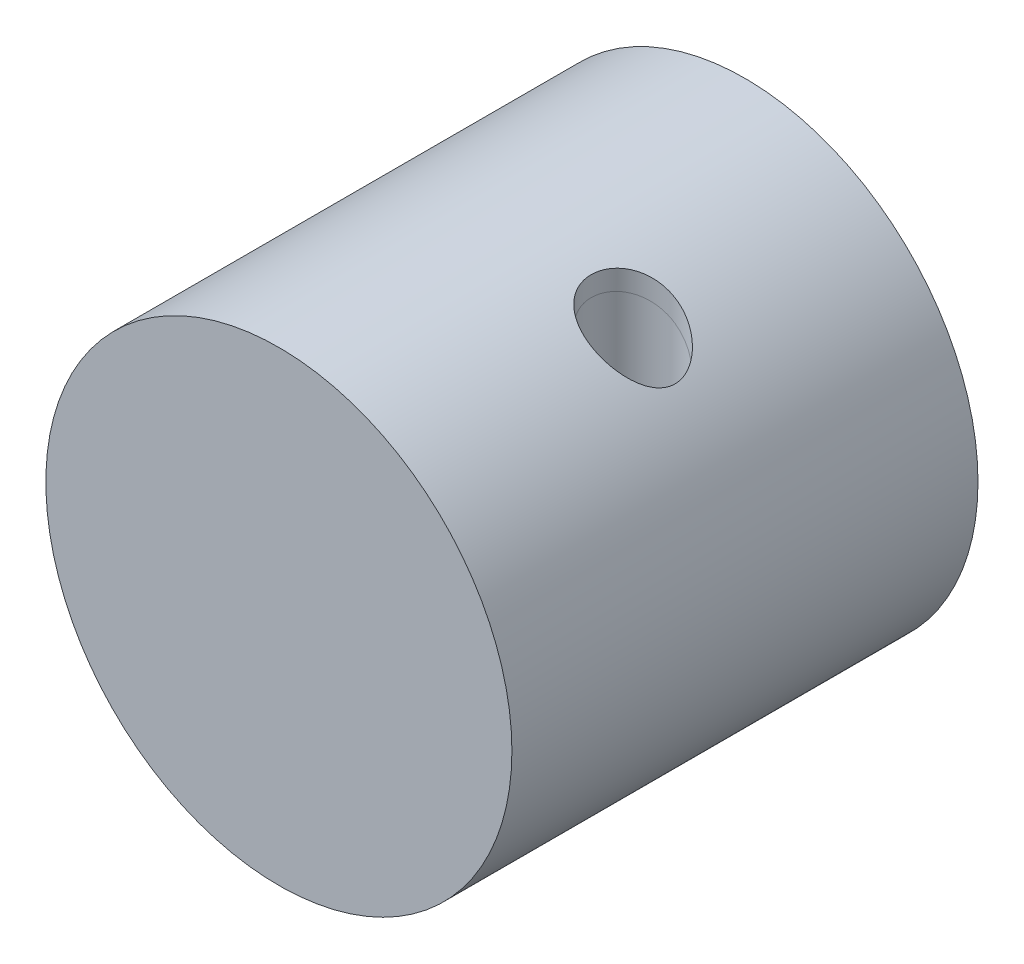
from build123d import *

# Parameters (mm, degrees)
SKIZZE1_R                       = 25
AUFSATZ_LINEAR_AUSTRAGEN1_DEPTH = 25
SKIZZE2_R                       = 4.5
SCHNITT_LINEAR_AUSTRAGEN1_DEPTH = 50


with BuildPart() as part:
    # Skizze1 → Aufsatz-Linear austragen1 (new body, symmetric)
    with BuildSketch(Plane.XY):
        Circle(SKIZZE1_R)
    extrude(amount=AUFSATZ_LINEAR_AUSTRAGEN1_DEPTH, both=True)

    # Skizze2 → Schnitt-Linear austragen1 (cut)
    with BuildSketch(Plane(origin=(0, 0, 0), x_dir=(1, 0, 0), z_dir=(0, 1, 0))):
        with Locations(Location((13, 0, 0), (0, 0, 90))):  # turned: the seam where the file's is
            Circle(SKIZZE2_R)
    extrude(amount=SCHNITT_LINEAR_AUSTRAGEN1_DEPTH, mode=Mode.SUBTRACT)


solid = part.part
